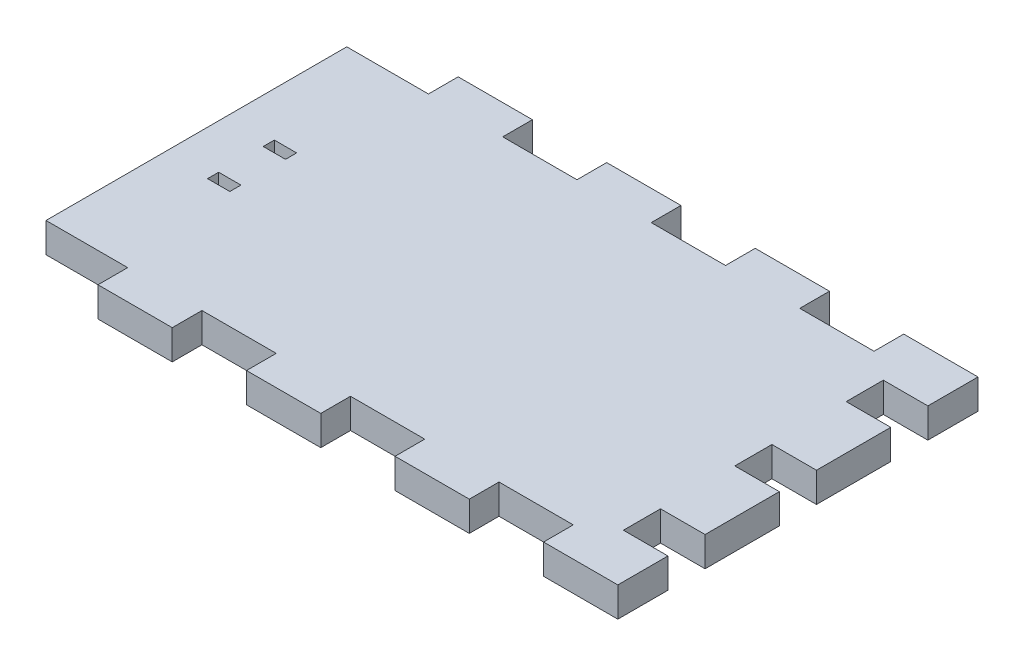
from build123d import *

# Parameters (mm, degrees)
SKETCH1_W           = 75
SKETCH1_H           = 40.5
BOSS_EXTRUDE1_DEPTH = 4
SKETCH2_W           = 2.75
SKETCH2_H           = 4
SKETCH2_W_2         = 10
BOSS_EXTRUDE2_DEPTH = 6
SKETCH3_W           = 10
SKETCH3_H           = 4
BOSS_EXTRUDE3_DEPTH = 4
LPATTERN1_COUNT     = 4
LPATTERN1_PITCH     = 20
SKETCH4_W           = 3
SKETCH4_H           = 1.5
CUT_EXTRUDE1_DEPTH  = 5


with BuildPart() as part:
    # Sketch1 → Boss-Extrude1 (new body)
    with BuildSketch(Plane(origin=(0, 0, 0), x_dir=(1, 0, 0), z_dir=(0, 1, 0))):
        with Locations((37.5, -20.25)):
            Rectangle(SKETCH1_W, SKETCH1_H)
    extrude(amount=BOSS_EXTRUDE1_DEPTH)

    # Sketch2 → Boss-Extrude2 (add)
    with BuildSketch(Plane(origin=(75, 0, 0), x_dir=(0, 0, -1), z_dir=(1, 0, 0))):
        with Locations((-39.125, 2)):
            Rectangle(SKETCH2_W, SKETCH2_H)
        with Locations((-27.75, 2)):
            Rectangle(SKETCH2_W_2, SKETCH2_H)
        with Locations((-12.75, 2)):
            Rectangle(SKETCH2_W_2, SKETCH2_H)
        with Locations((-1.375, 2)):
            Rectangle(SKETCH2_W, SKETCH2_H)
    extrude(amount=BOSS_EXTRUDE2_DEPTH)

    # Sketch3 → Boss-Extrude3 (add, through all)
    with BuildSketch(Plane(origin=(0, 4, 0), x_dir=(1, 0, 0), z_dir=(0, 1, 0))):
        with Locations((76, 2)):
            Rectangle(SKETCH3_W, SKETCH3_H)
        with Locations((76, -42.5)):
            Rectangle(SKETCH3_W, SKETCH3_H)
    boss_extrude3 = extrude(amount=-BOSS_EXTRUDE3_DEPTH)

    # LPattern1: Boss-Extrude3 ×4
    with Locations(*[(-i * LPATTERN1_PITCH, 0, 0) for i in range(1, LPATTERN1_COUNT)]):
        add(boss_extrude3)

    # Sketch4 → Cut-Extrude1 (cut, through all)
    with BuildSketch(Plane(origin=(0, 4, 0), x_dir=(1, 0, 0), z_dir=(0, 1, 0))):
        with Locations((7.5, -24)):
            Rectangle(SKETCH4_W, SKETCH4_H)
        with Locations((7.5, -16.5)):
            Rectangle(SKETCH4_W, SKETCH4_H)
    extrude(amount=-CUT_EXTRUDE1_DEPTH, mode=Mode.SUBTRACT)


solid = part.part
